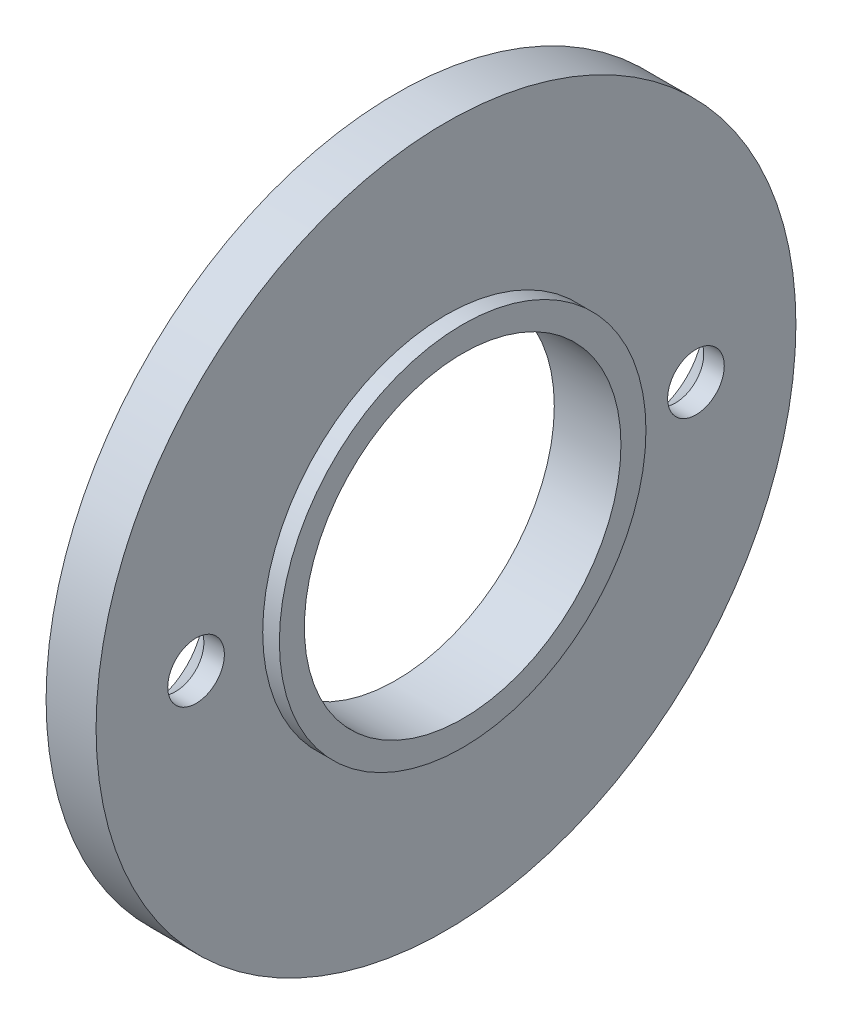
from build123d import *

# Parameters (mm, degrees)
CSK_FOR_M3_HEX_SOCKET_COUNTERSUNK_HE_2_COUNT = 2
CSK_FOR_M3_HEX_SOCKET_COUNTERSUNK_HE_2_PITCH = 30


with BuildPart() as part:
    # Sketch1 → Revolve1 (revolve)
    with BuildSketch(Plane(origin=(0, 0, 0), x_dir=(1, 0, 0), z_dir=(0, 1, 0))):
        Polygon((-1.5, 21), (1.5, 21), (1.5, 11), (2.5, 11), (2.5, 9.5), (-1.5, 9.5), align=None)
    revolve(axis=Axis((88.99, 0, 0), (-1, 0, 0)))

    # Sketch3 → CSK for M3 Hex Socket Countersunk Head S (revolve, cut)
    with BuildSketch(Plane(origin=(-1.5, 0, 15), x_dir=(0, 0, 1), z_dir=(0, 1, 0))):
        Polygon((0, 0), (0, 3), (1.7, 3), (1.7, 1.77), (3.47, 0), align=None)
    csk_for_m3_hex_socket_countersunk_head_s = revolve(axis=Axis((-7.85, 0, 15), (1, 0, 0)), mode=Mode.SUBTRACT)

    # CSK for M3 Hex Socket Countersunk He 2: CSK for M3 Hex Socket Countersunk Head S ×2
    with Locations(*[(0, 0, -i * CSK_FOR_M3_HEX_SOCKET_COUNTERSUNK_HE_2_PITCH) for i in range(1, CSK_FOR_M3_HEX_SOCKET_COUNTERSUNK_HE_2_COUNT)]):
        add(csk_for_m3_hex_socket_countersunk_head_s, mode=Mode.SUBTRACT)


solid = part.part
